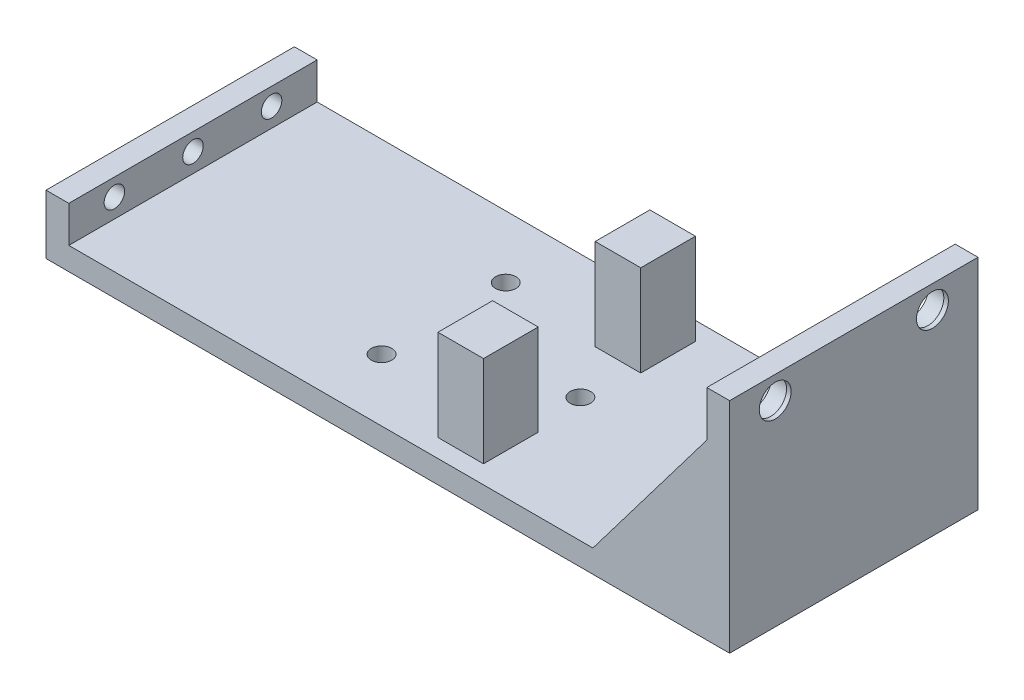
from build123d import *

# Parameters (mm, degrees)
SKETCH1_W                 = 150
SKETCH1_H                 = 54.5
BOSS_EXTRUDE1_DEPTH       = 5
SKETCH2_W                 = 5
SKETCH2_H                 = 54.5
BOSS_EXTRUDE2_DEPTH       = 8
F_8_CLEARANCE_HOLE1_D     = 4.4958
F_8_CLEARANCE_HOLE1_DEPTH = 17
F_8_CLEARANCE_HOLE1_TIP   = 1.350674586
SKETCH7_W                 = 5
SKETCH7_H                 = 54.5
BOSS_EXTRUDE3_DEPTH       = 43
SKETCH8_R                 = 4.25
CUT_EXTRUDE1_DEPTH        = 4
RIB1_REACH                = 120.085
SKETCH10_WALL_W           = 279.571445908
SKETCH10_WALL_H           = 10
RIB3_REACH                = 120.085
SKETCH12_WALL_W           = 279.571445908
SKETCH12_WALL_H           = 10
SKETCH13_W                = 8
SKETCH13_H                = 2
BOSS_EXTRUDE4_DEPTH       = 5
SKETCH14_R                = 2
CUT_EXTRUDE2_DEPTH        = 2
SKETCH15_R                = 3.5
CUT_EXTRUDE3_DEPTH        = 1
F_8_CLEARANCE_HOLE2_D     = 4.4958
F_8_CLEARANCE_HOLE2_DEPTH = 17
F_8_CLEARANCE_HOLE2_TIP   = 1.350674586
SKETCH16_W                = 10
SKETCH16_H                = 12
BOSS_EXTRUDE5_DEPTH       = 20
SKETCH18_W                = 7
SKETCH18_H                = 7
CUT_EXTRUDE4_DEPTH        = 8


with BuildPart() as part:
    # Sketch1 → Boss-Extrude1 (new body)
    with BuildSketch(Plane(origin=(0, 0, 0), x_dir=(1, 0, 0), z_dir=(0, 1, 0))):
        with Locations((-18.112463826, -1.689393939)):
            Rectangle(SKETCH1_W, SKETCH1_H)
    extrude(amount=BOSS_EXTRUDE1_DEPTH)

    # Sketch2 → Boss-Extrude2 (add)
    with BuildSketch(Plane(origin=(0, 5, 0), x_dir=(1, 0, 0), z_dir=(0, 1, 0))):
        with Locations((-90.612463826, -1.689393939)):
            Rectangle(SKETCH2_W, SKETCH2_H)
    extrude(amount=BOSS_EXTRUDE2_DEPTH)

    # #8 Clearance Hole1
    with Locations(Plane(origin=(-93.112463826, 9.2, -15.560606061), x_dir=(0, 0, -1), z_dir=(-1, 0, 0))):
        with Locations((0, 0), (-17.25, 0), (-34.5, 0)):
            Hole(F_8_CLEARANCE_HOLE1_D / 2, depth=F_8_CLEARANCE_HOLE1_DEPTH)
            with Locations((0, 0, -(F_8_CLEARANCE_HOLE1_DEPTH + F_8_CLEARANCE_HOLE1_TIP / 2))):  # 118° drill point
                Cone(0, F_8_CLEARANCE_HOLE1_D / 2, F_8_CLEARANCE_HOLE1_TIP, mode=Mode.SUBTRACT)

    # Sketch7 → Boss-Extrude3 (add)
    with BuildSketch(Plane(origin=(0, 5, 0), x_dir=(1, 0, 0), z_dir=(0, 1, 0))):
        with Locations((54.387536174, -1.689393939)):
            Rectangle(SKETCH7_W, SKETCH7_H)
    extrude(amount=BOSS_EXTRUDE3_DEPTH)

    # Sketch8 → Cut-Extrude1 (cut)
    with BuildSketch(Plane.ZY.offset(-51.887536174)):
        with Locations((-15.560606061, 43)):
            Circle(SKETCH8_R)
        with Locations((18.939393939, 43)):
            Circle(SKETCH8_R)
    extrude(amount=-CUT_EXTRUDE1_DEPTH, mode=Mode.SUBTRACT)

    # Sketch10 wall → Rib1 (add, up to next)
    with BuildSketch(Plane(origin=(39.387536174, 21.5, -25.560606061), x_dir=(-0.603857687995, -0.797092148154, 0), z_dir=(-0.797092148154, 0.603857687995, 0)), mode=Mode.PRIVATE) as rib1_sk1:
        with Locations((0, 5)):
            Rectangle(SKETCH10_WALL_W, SKETCH10_WALL_H)
    rib1_tool1 = extrude(rib1_sk1.sketch, amount=-RIB1_REACH, mode=Mode.PRIVATE) - part.part
    add(rib1_tool1.solids().sort_by_distance((39.387536174, 21.5, -25.560606061))[0])

    # Sketch12 wall → Rib3 (add, up to next)
    with BuildSketch(Plane(origin=(39.387536174, 21.5, 28.939393939), x_dir=(-0.603857687995, -0.797092148154, 0), z_dir=(0.797092148154, -0.603857687995, 0)), mode=Mode.PRIVATE) as rib3_sk1:
        with Locations((0, 5)):
            Rectangle(SKETCH12_WALL_W, SKETCH12_WALL_H)
    rib3_tool1 = extrude(rib3_sk1.sketch, amount=RIB3_REACH, mode=Mode.PRIVATE) - part.part
    add(rib3_tool1.solids().sort_by_distance((39.387536174, 21.5, 28.939393939))[0])

    # Sketch13 → Boss-Extrude4 (add)
    with BuildSketch(Plane.ZY.offset(-51.887536174)):
        with Locations((1.689393939, 37)):
            Rectangle(SKETCH13_W, SKETCH13_H)
    extrude(amount=BOSS_EXTRUDE4_DEPTH)

    # Sketch14 → Cut-Extrude2 (cut)
    with BuildSketch(Plane(origin=(0, 38, 0), x_dir=(1, 0, 0), z_dir=(0, 1, 0))):
        with Locations(Location((49.387536174, -1.689393939, 0), (0, 0, 270))):
            Circle(SKETCH14_R)
    extrude(amount=-CUT_EXTRUDE2_DEPTH, mode=Mode.SUBTRACT)

    # Sketch15 → Cut-Extrude3 (cut)
    with BuildSketch(Plane.ZY.offset(-55.887536174)):
        with Locations((-15.560606061, 43)):
            Circle(SKETCH15_R)
        with Locations((18.939393939, 43)):
            Circle(SKETCH15_R)
    extrude(amount=-CUT_EXTRUDE3_DEPTH, mode=Mode.SUBTRACT)

    # #8 Clearance Hole2
    with Locations(Plane(origin=(-3.112463826, 5, 1.689393939), x_dir=(0, 0, 1), z_dir=(0, 1, 0))):
        with Locations((0, 0), (13.625, -30), (-13.625, -30)):
            Hole(F_8_CLEARANCE_HOLE2_D / 2, depth=F_8_CLEARANCE_HOLE2_DEPTH)
            with Locations((0, 0, -(F_8_CLEARANCE_HOLE2_DEPTH + F_8_CLEARANCE_HOLE2_TIP / 2))):  # 118° drill point
                Cone(0, F_8_CLEARANCE_HOLE2_D / 2, F_8_CLEARANCE_HOLE2_TIP, mode=Mode.SUBTRACT)

    # Sketch16 → Boss-Extrude5 (add)
    with BuildSketch(Plane(origin=(0, 5, 0), x_dir=(1, 0, 0), z_dir=(0, 1, 0))):
        with Locations((-6.112463826, 15.560606061)):
            Rectangle(SKETCH16_W, SKETCH16_H)
        with Locations((-6.112463826, -18.939393939)):
            Rectangle(SKETCH16_W, SKETCH16_H)
    extrude(amount=BOSS_EXTRUDE5_DEPTH)

    # Sketch18 → Cut-Extrude4 (cut)
    with BuildSketch(Plane.ZY.offset(11.112463826)):
        with Locations((-15.560606061, 20)):
            Rectangle(SKETCH18_W, SKETCH18_H)
        with Locations((18.939393939, 20)):
            Rectangle(SKETCH18_W, SKETCH18_H)
    extrude(amount=-CUT_EXTRUDE4_DEPTH, mode=Mode.SUBTRACT)


solid = part.part
